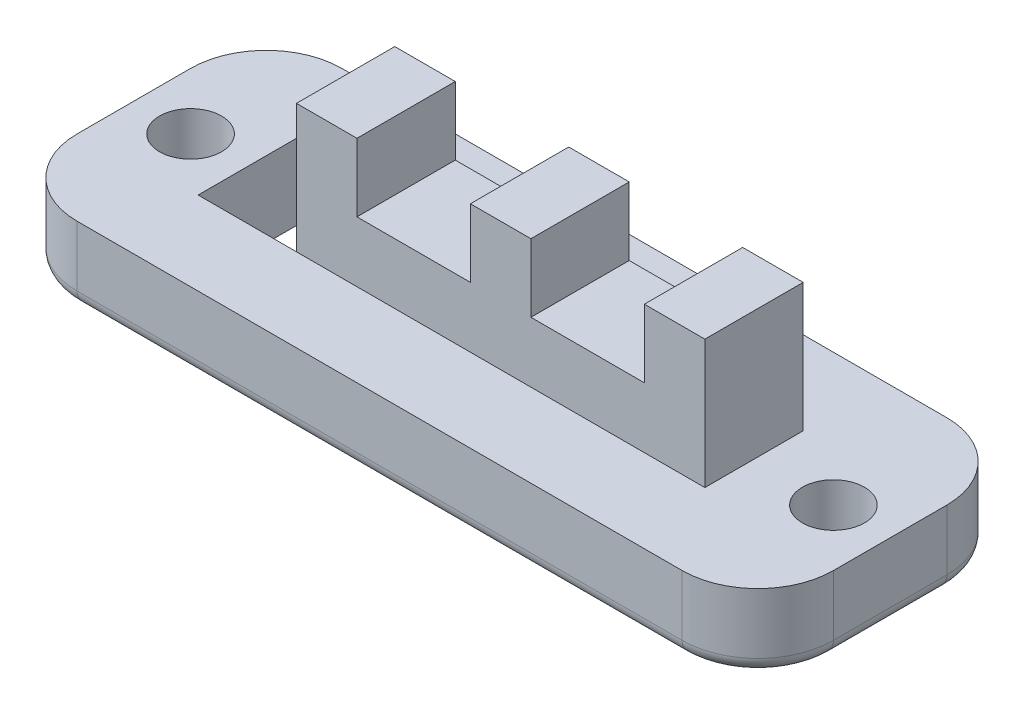
from build123d import *

# Parameters (mm, degrees)
SKETCH1_W           = 25.4
SKETCH1_H           = 8.89
BOSS_EXTRUDE1_DEPTH = 2.54
SKETCH2_W           = 17.018
SKETCH2_H           = 3.302
BOSS_EXTRUDE2_DEPTH = 2.032
SKETCH3_R           = 1.0414
CUT_EXTRUDE1_DEPTH  = 5.572
SKETCH4_W           = 3.302
SKETCH4_H           = 3.302
CUT_EXTRUDE2_DEPTH  = 4.572
SKETCH5_W           = 2.032
SKETCH5_H           = 3.302
BOSS_EXTRUDE3_DEPTH = 2.286
FILLET1_R           = 2.54
FILLET2_R           = 0.508


with BuildPart() as part:
    # Sketch1 → Boss-Extrude1 (new body)
    with BuildSketch(Plane(origin=(0, 0, 0), x_dir=(1, 0, 0), z_dir=(0, 1, 0))):
        Rectangle(SKETCH1_W, SKETCH1_H)
    extrude(amount=BOSS_EXTRUDE1_DEPTH)

    # Sketch2 → Boss-Extrude2 (add)
    with BuildSketch(Plane(origin=(0, 2.54, 0), x_dir=(1, 0, 0), z_dir=(0, 1, 0))):
        with Locations((-0.381, 0)):
            Rectangle(SKETCH2_W, SKETCH2_H)
    extrude(amount=BOSS_EXTRUDE2_DEPTH)

    # Sketch3 → Cut-Extrude1 (cut, through all)
    with BuildSketch(Plane.XZ):
        with Locations((-10.795, 0)):
            Circle(SKETCH3_R)
        with Locations((10.795, 0)):
            Circle(SKETCH3_R)
    extrude(amount=-CUT_EXTRUDE1_DEPTH, mode=Mode.SUBTRACT)

    # Sketch4 → Cut-Extrude2 (cut)
    with BuildSketch(Plane(origin=(0, 4.572, 0), x_dir=(1, 0, 0), z_dir=(0, 1, 0))):
        with Locations((-7.239, 0)):
            Rectangle(SKETCH4_W, SKETCH4_H)
    extrude(amount=-CUT_EXTRUDE2_DEPTH, mode=Mode.SUBTRACT)

    # Sketch5 → Boss-Extrude3 (add)
    with BuildSketch(Plane(origin=(0, 4.572, 0), x_dir=(1, 0, 0), z_dir=(0, 1, 0))):
        with Locations((-4.572, 0)):
            Rectangle(SKETCH5_W, SKETCH5_H)
        with Locations((1.27, 0)):
            Rectangle(SKETCH5_W, SKETCH5_H)
        with Locations((7.112, 0)):
            Rectangle(SKETCH5_W, SKETCH5_H)
    extrude(amount=BOSS_EXTRUDE3_DEPTH)

    # Fillet1
    fillet1_edges = [part.edges().sort_by_distance(p)[0] for p in [
        (12.7, 1.27, 4.445),
        (-12.7, 1.27, 4.445),
        (-12.7, 1.27, -4.445),
        (12.7, 1.27, -4.445),
    ]]
    fillet(fillet1_edges, radius=FILLET1_R)

    # Fillet2
    fillet2_edges = [part.edges().sort_by_distance(p)[0] for p in [
        (12.7, 0, 0),
        (0, 0, 4.445),
        (-12.7, 0, 0),
        (0, 0, -4.445),
        (-11.956051224, 0, -3.701051224),
        (-11.956051224, 0, 3.701051224),
        (11.956051224, 0, -3.701051224),
        (11.956051224, 0, 3.701051224),
    ]]
    fillet(fillet2_edges, radius=FILLET2_R)


solid = part.part
